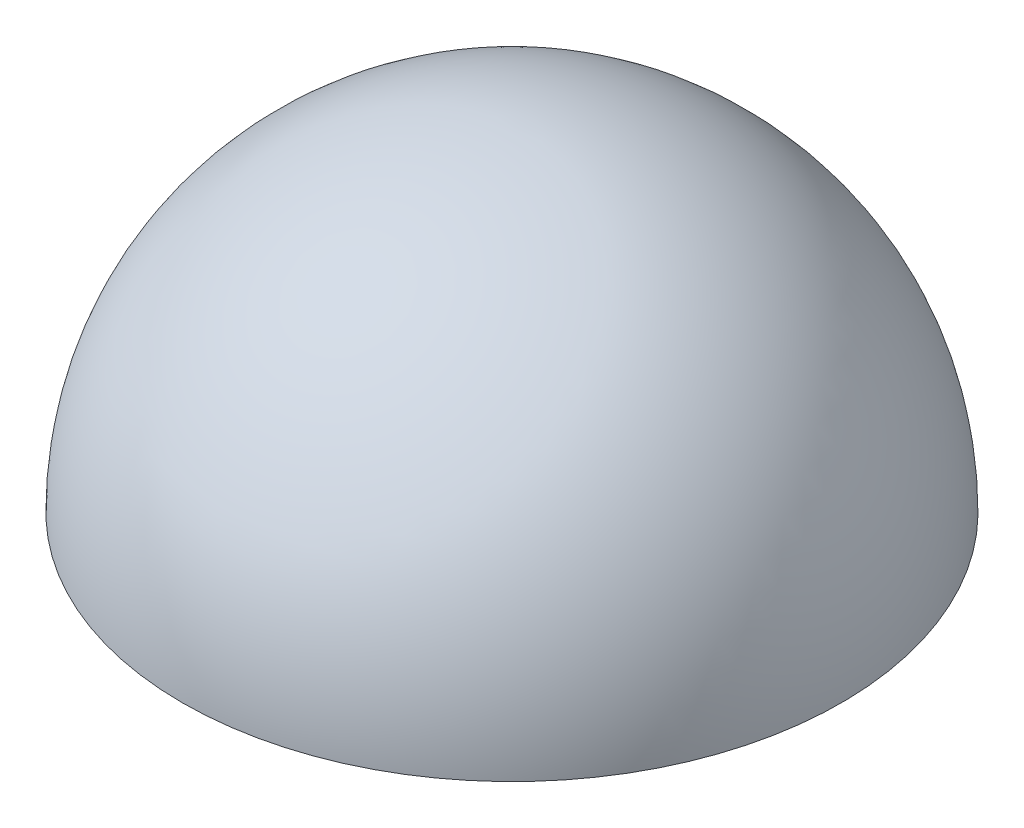
from build123d import *

# Parameters (mm, degrees)
REVOLVE1_ANGLE      = 180
SKETCH2_R           = 24.825
SKETCH2_R_2         = 23
CUT_EXTRUDE1_DEPTH  = 2.15
BOSS_EXTRUDE1_DEPTH = 1.05


with BuildPart() as part:
    # Sketch1 → Revolve1 (revolve)
    with BuildSketch(Plane(origin=(0, 0, 0), x_dir=(1, 0, 0), z_dir=(0, 1, 0))):
        with BuildLine():
            Line((0, 25.25), (0, 23.25))
            ThreePointArc((0, 23.25), (23.25, 0), (0, -23.25))
            Line((0, -23.25), (0, -25.25))
            ThreePointArc((0, -25.25), (25.25, 0), (0, 25.25))
        make_face()
    revolve(axis=Axis((0, 0, 23.25), (0, 0, 1)), revolution_arc=REVOLVE1_ANGLE)

    # Sketch2 → Cut-Extrude1 (cut)
    with BuildSketch(Plane.XZ):
        Circle(SKETCH2_R)
        Circle(SKETCH2_R_2, mode=Mode.SUBTRACT)
    extrude(amount=-CUT_EXTRUDE1_DEPTH, mode=Mode.SUBTRACT)

    # Sketch3 → Boss-Extrude1 (add)
    with BuildSketch(Plane.XZ):
        with BuildLine():
            Line((-5.134436401, 24.288231468), (-5, 23.65228583))
            ThreePointArc((-5, 23.65228583), (0, 24.175), (5, 23.65228583))
            Line((5, 23.65228583), (5, 24.316262562))
            ThreePointArc((5, 24.316262562), (-0.068663834, 24.824905041), (-5.134436401, 24.288231468))
        make_face()
        with BuildLine():
            Line((23.601443665, -7.697563376), (22.983480387, -7.496015896))
            ThreePointArc((22.983480387, -7.496015896), (20.936164136, -12.0875), (17.983480387, -16.156269934))
            Line((17.983480387, -16.156269934), (18.558501104, -16.4882583))
            ThreePointArc((18.558501104, -16.4882583), (21.533330329, -12.352987896), (23.601443665, -7.697563376))
        make_face()
        with BuildLine():
            Line((-18.467007264, -16.590668092), (-17.983480387, -16.156269934))
            ThreePointArc((-17.983480387, -16.156269934), (-20.936164136, -12.0875), (-22.983480387, -7.496015896))
            Line((-22.983480387, -7.496015896), (-23.558501104, -7.828004262))
            ThreePointArc((-23.558501104, -7.828004262), (-21.464666495, -12.471917145), (-18.467007264, -16.590668092))
        make_face()
    extrude(amount=-BOSS_EXTRUDE1_DEPTH)


solid = part.part
